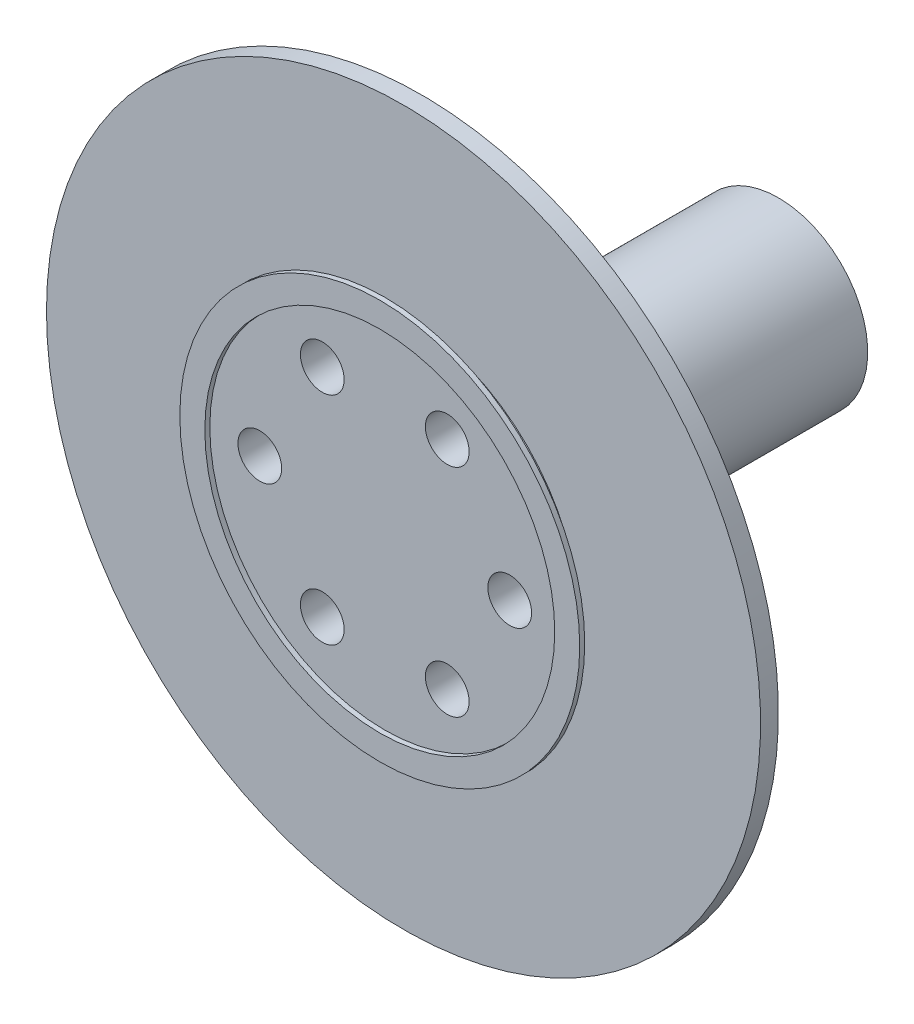
from build123d import *

# Parameters (mm, degrees)
SKETCH_1_R          = 16
SKETCH_1_R_2        = 14
EXTRUDE_1_DEPTH     = 0.4
SKETCH_2_R          = 14
EXTRUDE_1_2_DEPTH   = 1.5
SKETCH_3_R          = 1.75
CUT_EXTRUDE_1_DEPTH = 1.5
SCALE_1_SCALE       = 0.35
SKETCH_4_R          = 10
SKETCH_4_R_2        = 0.6125
EXTRUDE_2_DEPTH     = 0.5
SKETCH_5_R          = 2.5
EXTRUDE_3_DEPTH     = 10


with BuildPart() as part:
    # 草图1 → Extrude 1 (new body)
    with BuildSketch(Plane.XY):
        Circle(SKETCH_1_R)
        Circle(SKETCH_1_R_2, mode=Mode.SUBTRACT)
    extrude(amount=EXTRUDE_1_DEPTH)


with BuildPart() as body_2:
    # 草图2 → Extrude 1 2 (new body)
    with BuildSketch(Plane(origin=(0, 0, 0), x_dir=(-1, 0, 0), z_dir=(0, 0, -1))):
        Circle(SKETCH_2_R)
    extrude(amount=EXTRUDE_1_2_DEPTH)

    # 草图3 → 切除-拉伸1 (cut)
    with BuildSketch(Plane.XY):
        with Locations((10, 0)):
            Circle(SKETCH_3_R)
        with Locations((5, -8.660254038)):
            Circle(SKETCH_3_R)
        with Locations((-5, -8.660254038)):
            Circle(SKETCH_3_R)
        with Locations((-10, 0)):
            Circle(SKETCH_3_R)
        with Locations((-5, 8.660254038)):
            Circle(SKETCH_3_R)
        with Locations((5, 8.660254038)):
            Circle(SKETCH_3_R)
    extrude(amount=-CUT_EXTRUDE_1_DEPTH, mode=Mode.SUBTRACT)


with BuildPart() as part_1:
    # 缩放比例1: scaled about (0, 0, 0)
    add(part.part.scale(SCALE_1_SCALE))


with BuildPart() as body_2_1:
    # 缩放比例1: scaled about (0, 0, 0)
    add(body_2.part.scale(SCALE_1_SCALE))

    # 草图4 → 凸台-拉伸2 (add)
    with BuildSketch(Plane(origin=(0, 0, -0.525), x_dir=(-1, 0, 0), z_dir=(0, 0, -1))):
        Circle(SKETCH_4_R)
        with Locations(Location((1.75, -3.031088913, 0), (0, 0, 180))):
            Circle(SKETCH_4_R_2, mode=Mode.SUBTRACT)
        with Locations(Location((-1.75, -3.031088913, 0), (0, 0, 180))):
            Circle(SKETCH_4_R_2, mode=Mode.SUBTRACT)
        with Locations(Location((-3.5, 0, 0), (0, 0, 180))):
            Circle(SKETCH_4_R_2, mode=Mode.SUBTRACT)
        with Locations(Location((-1.75, 3.031088913, 0), (0, 0, 180))):
            Circle(SKETCH_4_R_2, mode=Mode.SUBTRACT)
        with Locations(Location((1.75, 3.031088913, 0), (0, 0, 180))):
            Circle(SKETCH_4_R_2, mode=Mode.SUBTRACT)
        with Locations(Location((3.5, 0, 0), (0, 0, 180))):
            Circle(SKETCH_4_R_2, mode=Mode.SUBTRACT)
    extrude(amount=EXTRUDE_2_DEPTH)

    # 草图5 → 凸台-拉伸3 (add)
    with BuildSketch(Plane(origin=(0, 0, -1.025), x_dir=(-1, 0, 0), z_dir=(0, 0, -1))):
        Circle(SKETCH_5_R)
        with BuildLine():
            Line((-1.2489996, 1), (1.2489996, 1))
            ThreePointArc((1.2489996, 1), (0, -1.6), (-1.2489996, 1))
        make_face(mode=Mode.SUBTRACT)
    extrude(amount=EXTRUDE_3_DEPTH)


solid = Compound([part_1.part, body_2_1.part])
